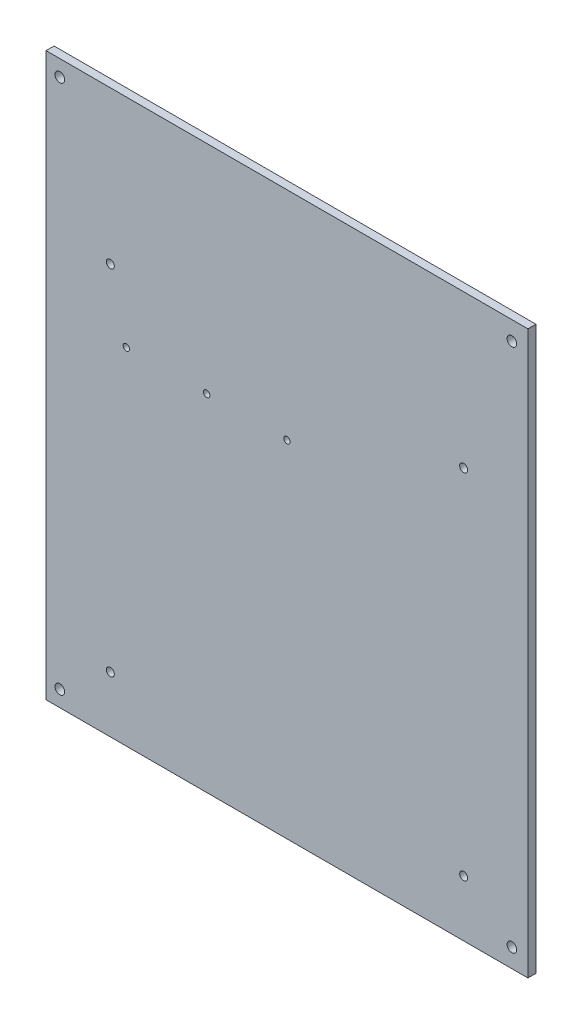
from build123d import *

# Parameters (mm, degrees)
SKETCH1_W           = 300
SKETCH1_H           = 350
SKETCH1_R           = 3
BOSS_EXTRUDE1_DEPTH = 5
SKETCH2_R           = 2.5
CUT_EXTRUDE1_DEPTH  = 10
SKETCH3_R           = 2
CUT_EXTRUDE2_DEPTH  = 6


with BuildPart() as part:
    # Sketch1 → Boss-Extrude1 (new body)
    with BuildSketch(Plane.XY):
        Rectangle(SKETCH1_W, SKETCH1_H)
        with Locations((-141.428571429, 165)):
            Circle(SKETCH1_R, mode=Mode.SUBTRACT)
        with Locations((140, 163.333333333)):
            Circle(SKETCH1_R, mode=Mode.SUBTRACT)
        with Locations((140, -163.333333333)):
            Circle(SKETCH1_R, mode=Mode.SUBTRACT)
        with Locations((-141.428571429, -165)):
            Circle(SKETCH1_R, mode=Mode.SUBTRACT)
    extrude(amount=BOSS_EXTRUDE1_DEPTH)

    # Sketch2 → Cut-Extrude1 (cut)
    with BuildSketch(Plane(origin=(0, 0, 0), x_dir=(-1, 0, 0), z_dir=(0, 0, -1))):
        with Locations((110, -140)):
            Circle(SKETCH2_R)
        with Locations((-110, -140)):
            Circle(SKETCH2_R)
        with Locations((-110, 80)):
            Circle(SKETCH2_R)
        with Locations((110, 80)):
            Circle(SKETCH2_R)
    extrude(amount=-CUT_EXTRUDE1_DEPTH, mode=Mode.SUBTRACT)

    # Sketch3 → Cut-Extrude2 (cut, through all)
    with BuildSketch(Plane(origin=(0, 0, 0), x_dir=(-1, 0, 0), z_dir=(0, 0, -1))):
        with Locations((0, 40)):
            Circle(SKETCH3_R)
        with Locations((50, 40)):
            Circle(SKETCH3_R)
        with Locations((100, 40)):
            Circle(SKETCH3_R)
    extrude(amount=-CUT_EXTRUDE2_DEPTH, mode=Mode.SUBTRACT)


solid = part.part
